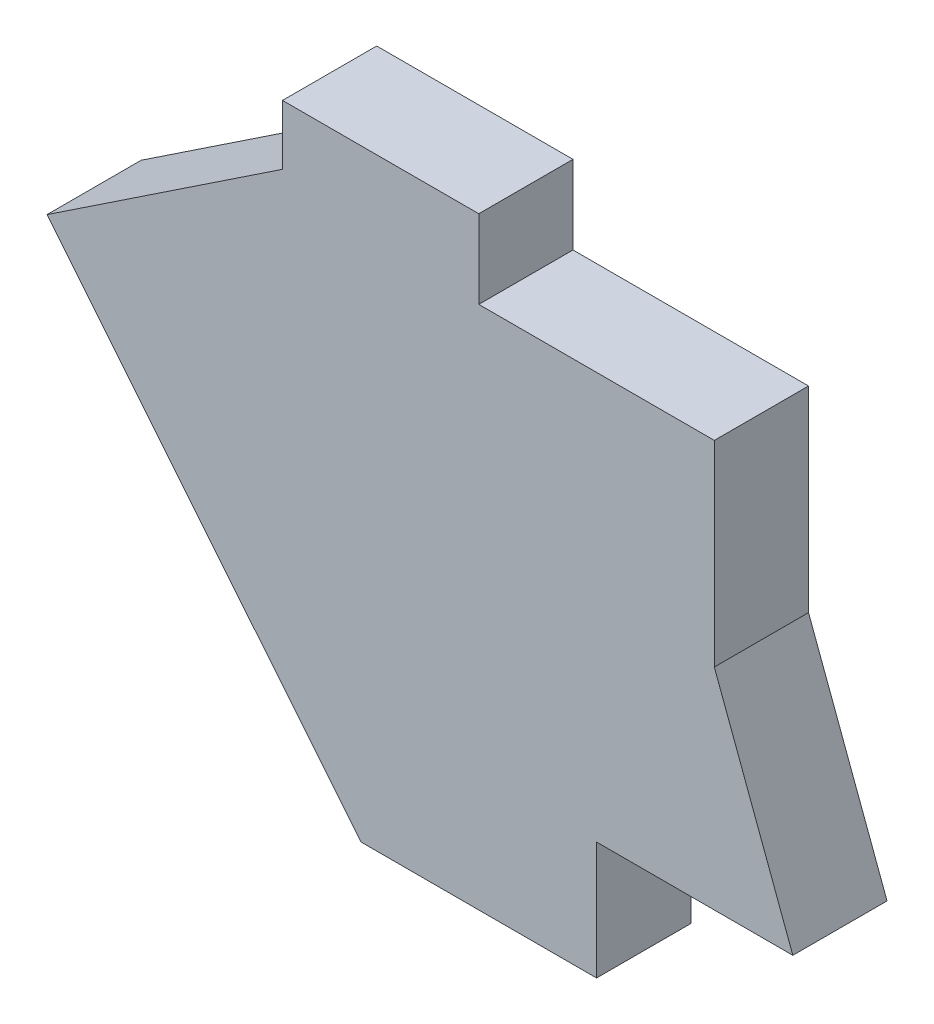
from build123d import *

# Parameters (mm, degrees)
BOSS_EXTRUDE1_DEPTH = 15.24


with BuildPart() as part:
    # Sketch1 → Boss-Extrude1 (new body)
    with BuildSketch(Plane.XY):
        Polygon((-19.05, -60.265205079), (-69.85, 2.218794921), (-31.75, 27.618794921), (-31.75, 37.270794921), (0, 37.270794921), (0, 24.570794921), (38.1, 24.570794921), (38.1, -7.179205079), (50.8, -41.215205079), (19.05, -41.215205079), (19.05, -60.265205079), align=None)
    extrude(amount=BOSS_EXTRUDE1_DEPTH)


solid = part.part
